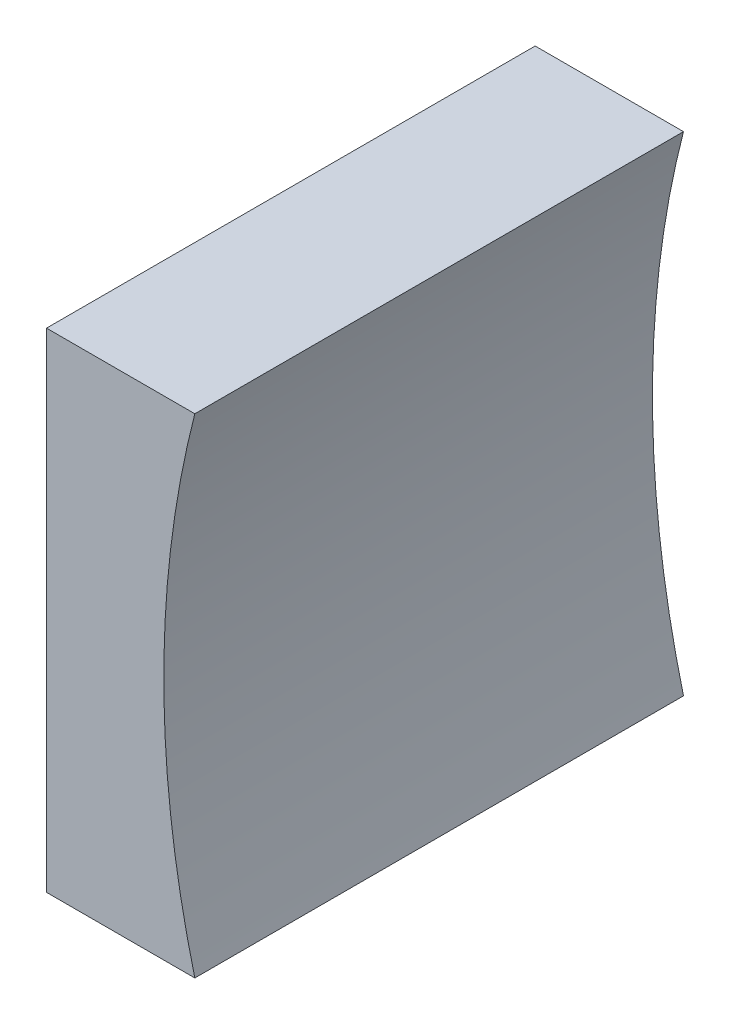
from build123d import *

# Parameters (mm, degrees)
EXTRUDE_1_DEPTH = 25


with BuildPart() as part:
    # 草图1 → 凸台-拉伸1 (new body)
    with BuildSketch(Plane.XY):
        with BuildLine():
            Line((284.707135631, 66.857929268), (284.707135631, 79.357929268))
            Line((284.707135631, 79.357929268), (292.294843804, 79.357929268))
            ThreePointArc((292.294843804, 79.357929268), (290.707135631, 66.857929268), (292.294843804, 54.357929268))
            Line((292.294843804, 54.357929268), (284.707135631, 54.357929268))
            Line((284.707135631, 54.357929268), (284.707135631, 66.857929268))
        make_face()
    extrude(amount=EXTRUDE_1_DEPTH)


solid = part.part
